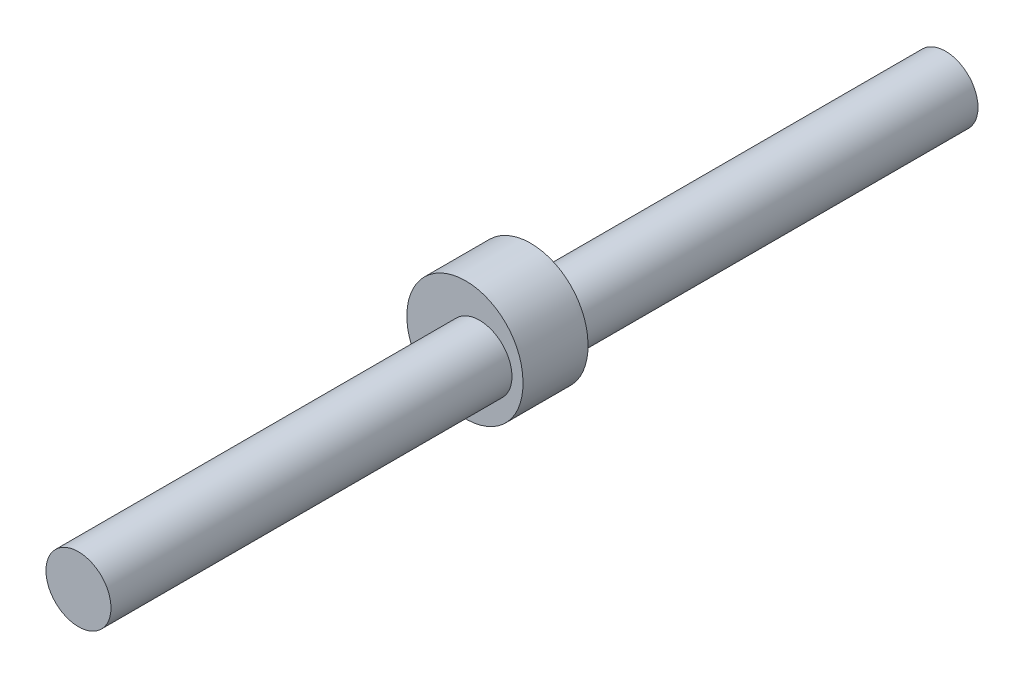
from build123d import *

# Parameters (mm, degrees)
BOSS_EXTRUDE1_DEPTH = 15
SKETCH3_R           = 15
BOSS_EXTRUDE2_DEPTH = 185


with BuildPart() as part:
    # Sketch2 → Boss-Extrude1 (new body, symmetric)
    with BuildSketch(Plane.XY):
        with BuildLine():
            add(Edge.make_bspline(
                [(20.1, 0), (20.099865774, 0.058549027), (20.099720739, 0.175649053), (20.098104632, 0.35129807), (20.095563684, 0.526947006), (20.091970511, 0.702595812), (20.087358573, 0.878244425), (20.08171813, 1.053892769), (20.075050658, 1.229540741), (20.06735461, 1.405188221), (20.058628907, 1.580835055), (20.048872259, 1.75648106), (20.038083185, 1.932126015), (20.026260057, 2.107769658), (20.013401137, 2.283411684), (19.999504479, 2.459051737), (19.984568023, 2.634689411), (19.968589576, 2.810324243), (19.951566785, 2.985955711), (19.933497107, 3.161583223), (19.914377952, 3.33720613), (19.894206459, 3.512823695), (19.872979789, 3.688435126), (19.850694789, 3.864039528), (19.827348341, 4.039635947), (19.802937009, 4.215223317), (19.777457405, 4.390800507), (19.750905849, 4.566366268), (19.723278664, 4.741919273), (19.694571969, 4.91745808), (19.66478173, 5.092981141), (19.633903929, 5.26848682), (19.601934228, 5.443973336), (19.568868351, 5.619438825), (19.534701772, 5.794881278), (19.499429942, 5.970298583), (19.463048166, 6.145688494), (19.425551633, 6.321048635), (19.386935424, 6.496376501), (19.347194523, 6.671669451), (19.306323839, 6.846924712), (19.264318125, 7.022139355), (19.221172104, 7.197310324), (19.176880377, 7.372434409), (19.131437416, 7.547508239), (19.084837698, 7.722528316), (19.037075545, 7.897490963), (18.988145195, 8.072392347), (18.938040965, 8.247228523), (18.886756533, 8.421995197), (18.834287426, 8.596688547), (18.780622304, 8.771302301), (18.72577487, 8.945838447), (18.669665072, 9.120267351), (18.612563037, 9.294676754), (18.552908395, 9.47024671), (18.49510864, 9.646799726), (18.434348602, 9.820938051), (18.36994419, 9.992344857), (18.307843693, 10.164870403), (18.242971673, 10.338476608), (18.177103311, 10.512044321), (18.109904186, 10.685447483), (18.041455828, 10.858711534), (17.971728109, 11.031821017), (17.900720772, 11.204771166), (17.828425593, 11.377554127), (17.754836457, 11.550162616), (17.679946664, 11.722588933), (17.603749748, 11.89482527), (17.526239092, 12.06686355), (17.447408186, 12.238695539), (17.36725053, 12.410312791), (17.285759627, 12.581706653), (17.20292898, 12.752868254), (17.118752183, 12.923788549), (17.033222829, 13.094458269), (16.946334525, 13.264867929), (16.858080999, 13.435007876), (16.768455925, 13.604868196), (16.677453116, 13.774438817), (16.585066409, 13.943709441), (16.491289677, 14.112669552), (16.396116902, 14.281308452), (16.299542137, 14.449615239), (16.201559426, 14.617578748), (16.102163051, 14.785187708), (16.001347186, 14.952430526), (15.899106263, 15.119295513), (15.795434709, 15.285770703), (15.690327065, 15.45184395), (15.583777996, 15.617502909), (15.47578225, 15.782735028), (15.366334707, 15.947527563), (15.255430333, 16.111867546), (15.143064252, 16.275741839), (15.02923168, 16.439137087), (14.91392799, 16.602039762), (14.797148632, 16.764436094), (14.678889274, 16.926312176), (14.559145672, 17.087653872), (14.437913705, 17.248446842), (14.315189508, 17.408676632), (14.190969236, 17.568328501), (14.065249313, 17.727387602), (13.938026234, 17.885838841), (13.809296756, 18.043667013), (13.679057749, 18.200856691), (13.547306243, 18.357392252), (13.414039495, 18.513257936), (13.279254941, 18.668437811), (13.142950177, 18.822915748), (13.005122991, 18.976675459), (12.865771422, 19.129700525), (12.724893628, 19.281974306), (12.58248804, 19.433480052), (12.438553258, 19.584200834), (12.293088121, 19.734119586), (12.146091642, 19.883219057), (11.997563117, 20.031481899), (11.847501999, 20.178890567), (11.695908009, 20.325427414), (11.542781108, 20.47107466), (11.388121432, 20.615814332), (11.231929424, 20.759628397), (11.074205735, 20.902498669), (10.914951256, 21.044406817), (10.754167123, 21.1853344), (10.591854769, 21.325262905), (10.428015807, 21.464173631), (10.262652172, 21.602047825), (10.09576602, 21.738866602), (9.927359791, 21.874610989), (9.757436183, 22.009261915), (9.585998175, 22.142800224), (9.413048988, 22.275206636), (9.238592168, 22.406461843), (9.06263147, 22.536546381), (8.885171021, 22.665440819), (8.706215125, 22.793125526), (8.525768463, 22.919580917), (8.343835953, 23.044787284), (8.160422816, 23.168724867), (7.975534557, 23.291373853), (7.789177006, 23.412714421), (7.601356249, 23.53272665), (7.41207869, 23.651390598), (7.221351043, 23.768686319), (7.029180284, 23.884593753), (6.83557384, 23.999093123), (6.640538892, 24.11216347), (6.444084952, 24.223788095), (6.246214385, 24.333934475), (6.046957582, 24.442629003), (5.846241724, 24.549677838), (5.644381692, 24.65571143), (5.440242271, 24.758273935), (5.239563697, 24.865693275), (5.023439999, 24.945695215), (4.826141087, 25.06584418), (4.612962346, 25.158738273), (4.403542937, 25.256252359), (4.191880407, 25.350222834), (3.979167353, 25.443009062), (3.76509837, 25.533951725), (3.549771111, 25.623202972), (3.33317534, 25.710697009), (3.115330183, 25.796426605), (2.896247307, 25.880368943), (2.675940792, 25.9625055), (2.454424469, 26.042816686), (2.231712642, 26.121283305), (2.007819903, 26.197886195), (1.782761169, 26.272606306), (1.556551672, 26.345424686), (1.329206969, 26.416322508), (1.100742936, 26.485281071), (0.871175764, 26.552281772), (0.640521955, 26.617306136), (0.408798345, 26.680335879), (0.176022066, 26.741352785), (-0.057789425, 26.800338829), (-0.292618365, 26.857276111), (-0.528446671, 26.912146926), (-0.765255955, 26.964933709), (-1.003027528, 27.015619021), (-1.241742381, 27.064185674), (-1.481381204, 27.110616627), (-1.721924396, 27.154894966), (-1.963352029, 27.197004092), (-2.205643904, 27.236927456), (-2.448779506, 27.274648812), (-2.692738029, 27.310152088), (-2.937498379, 27.343421418), (-3.183039165, 27.374441155), (-3.429338715, 27.403195846), (-3.676375062, 27.429670336), (-3.924125967, 27.45384961), (-4.172568899, 27.475718997), (-4.421681065, 27.495263919), (-4.671439381, 27.512470213), (-4.921820505, 27.527323809), (-5.172800816, 27.539811052), (-5.424356437, 27.54991839), (-5.676463224, 27.557632646), (-5.929096774, 27.562940891), (-6.182232433, 27.565830436), (-6.435845291, 27.566288908), (-6.689910193, 27.564304203), (-6.944401738, 27.559864514), (-7.199294287, 27.552958347), (-7.454561959, 27.543574421), (-7.710178647, 27.531701902), (-7.96611801, 27.51733013), (-8.222353485, 27.500448822), (-8.478858291, 27.481048027), (-8.735605421, 27.459118017), (-8.99256767, 27.434649534), (-9.249717615, 27.407633537), (-9.507027633, 27.378061345), (-9.764469904, 27.34592463), (-10.022016412, 27.311215379), (-10.279638955, 27.273925972), (-10.537309142, 27.234049078), (-10.794998408, 27.191577752), (-11.052678005, 27.146505376), (-11.310319027, 27.098825733), (-11.567892392, 27.048532926), (-11.825368868, 26.995621466), (-12.082719055, 26.940086169), (-12.339913425, 26.881922307), (-12.59692228, 26.821125431), (-12.853715805, 26.757691547), (-13.110264048, 26.691617036), (-13.366536909, 26.62289858), (-13.622504201, 26.551533384), (-13.878135583, 26.477518895), (-14.133400635, 26.400853079), (-14.388268805, 26.321534201), (-14.642709465, 26.23956099), (-14.896691877, 26.154932547), (-15.150185206, 26.067648323), (-15.403158567, 25.977708298), (-15.655580969, 25.88511274), (-15.907421352, 25.789862354), (-16.158648628, 25.691958322), (-16.409231589, 25.591402107), (-16.659139033, 25.488195724), (-16.90833967, 25.382341515), (-17.156802186, 25.273842257), (-17.404495233, 25.162701146), (-17.651387454, 25.048921838), (-17.897447415, 24.932508307), (-18.142643727, 24.813465058), (-18.386944965, 24.691796969), (-18.63031968, 24.567509294), (-18.872736487, 24.440607852), (-19.114163919, 24.311098686), (-19.354570625, 24.178988466), (-19.593925203, 24.044284144), (-19.832196309, 23.906993164), (-20.069352629, 23.767123367), (-20.305362895, 23.624683046), (-20.54019588, 23.479680904), (-20.773820408, 23.332126063), (-21.006205376, 23.1820281), (-21.237319745, 23.02939701), (-21.467132532, 22.874243181), (-21.695612848, 22.716577447), (-21.922729913, 22.556411104), (-22.148452996, 22.393755819), (-22.37275146, 22.228623671), (-22.595594857, 22.061027268), (-22.816952744, 21.890979495), (-23.036794863, 21.718493763), (-23.255091059, 21.543583855), (-23.471811313, 21.366263995), (-23.686925735, 21.186548797), (-23.900404608, 21.004453339), (-24.1122183, 20.819993032), (-24.322337426, 20.633183806), (-24.530732675, 20.444041904), (-24.737374976, 20.25258405), (-24.942235365, 20.058827296), (-25.145285138, 19.862789191), (-25.346495725, 19.66448763), (-25.545838759, 19.463940922), (-25.743286071, 19.26116776), (-25.938809691, 19.056187237), (-26.132381924, 18.849018888), (-26.323975179, 18.639682542), (-26.513562203, 18.428198518), (-26.701115889, 18.214587446), (-26.886609429, 17.998870387), (-27.070016188, 17.781068717), (-27.251309853, 17.561204257), (-27.430464316, 17.339299167), (-27.607453764, 17.115375994), (-27.782252562, 16.889457592), (-27.954835486, 16.661567272), (-28.125177472, 16.43172863), (-28.293253803, 16.199965656), (-28.459039964, 15.966302634), (-28.622511868, 15.730764283), (-28.783645605, 15.493375588), (-28.942417628, 15.254161916), (-29.098804679, 15.013148955), (-29.25278381, 14.770362723), (-29.404332401, 14.525829559), (-29.553428175, 14.279576146), (-29.70004913, 14.031629444), (-29.844173668, 13.78201678), (-29.98578045, 13.530765734), (-30.124848547, 13.277904233), (-30.261357361, 13.023460488), (-30.395286607, 12.767462985), (-30.526616411, 12.509940529), (-30.65532723, 12.250922191), (-30.781399886, 11.99043732), (-30.9048156, 11.728515556), (-31.025555923, 11.465186781), (-31.14360283, 11.200481167), (-31.258938635, 10.934429121), (-31.371546073, 10.667061319), (-31.481408251, 10.398408671), (-31.588508705, 10.128502348), (-31.692831289, 9.857373723), (-31.794360344, 9.585054434), (-31.893080578, 9.311576326), (-31.988977089, 9.036971457), (-32.082035456, 8.761272119), (-32.172241584, 8.484510782), (-32.259581867, 8.206720144), (-32.344043052, 7.927933069), (-32.425612418, 7.648182648), (-32.504277546, 7.367502111), (-32.58002656, 7.085924904), (-32.652847894, 6.803484604), (-32.722730562, 6.520214993), (-32.789663892, 6.236149973), (-32.853637732, 5.951323625), (-32.914642334, 5.66577016), (-32.972668396, 5.379523929), (-33.027707075, 5.092619419), (-33.079749985, 4.805091242), (-33.128789184, 4.516974127), (-33.174817149, 4.228302911), (-33.217826887, 3.939112548), (-33.257811771, 3.649438079), (-33.294765744, 3.359314651), (-33.328683077, 3.068777482), (-33.359558578, 2.777861877), (-33.38738755, 2.486603218), (-33.412165666, 2.195036943), (-33.43388913, 1.903198556), (-33.45255462, 1.611123612), (-33.468159196, 1.318847708), (-33.480700497, 1.026406485), (-33.490176517, 0.733835612), (-33.49658582, 0.441170785), (-33.499927392, 0.148447719), (-33.500200618, -0.144297861), (-33.497405512, -0.437030225), (-33.491542393, -0.729713644), (-33.482612141, -1.022312397), (-33.470616065, -1.314790781), (-33.455556006, -1.607113116), (-33.437434145, -1.899243747), (-33.416253262, -2.191147058), (-33.392016538, -2.482787478), (-33.364727607, -2.774129479), (-33.334390618, -3.065137598), (-33.301010104, -3.355776424), (-33.264591197, -3.646010632), (-33.225139308, -3.935804952), (-33.182660469, -4.225124217), (-33.137161073, -4.513933339), (-33.088648025, -4.80219733), (-33.037128641, -5.089881303), (-32.982610729, -5.376950483), (-32.925102532, -5.663370213), (-32.864612715, -5.949105947), (-32.801150473, -6.234123291), (-32.734725349, -6.518387962), (-32.665347389, -6.801865835), (-32.593027076, -7.084522931), (-32.517775307, -7.366325417), (-32.439603458, -7.647239635), (-32.358523301, -7.927232087), (-32.27454704, -8.206269446), (-32.187687335, -8.484318573), (-32.097957232, -8.7613465), (-32.005370284, -9.037320484), (-31.909940341, -9.312207935), (-31.811681753, -9.585976498), (-31.7106093, -9.858594032), (-31.60673809, -10.130028583), (-31.500083705, -10.400248445), (-31.39066212, -10.669222137), (-31.278489679, -10.936918397), (-31.163583136, -11.203306205), (-31.0459597, -11.468354817), (-30.925636831, -11.732033677), (-30.802632522, -11.994312555), (-30.676965039, -12.255161426), (-30.548653088, -12.514550564), (-30.417715723, -12.772450506), (-30.284172343, -13.028832054), (-30.148042734, -13.283666303), (-30.009347094, -13.536924659), (-29.868105834, -13.788578748), (-29.724339882, -14.038600584), (-29.578070388, -14.286962411), (-29.429318923, -14.533636834), (-29.278107313, -14.778596716), (-29.124457787, -15.021815278), (-28.968392862, -15.263266036), (-28.809935384, -15.502922842), (-28.649108543, -15.740759892), (-28.485935771, -15.976751669), (-28.320440871, -16.21087304), (-28.152647927, -16.443099199), (-27.982581325, -16.673405694), (-27.810265676, -16.901768366), (-27.635725982, -17.128163503), (-27.458987457, -17.352567687), (-27.280075588, -17.574957874), (-27.099016143, -17.79531138), (-26.915835175, -18.013605923), (-26.730558939, -18.229819527), (-26.543213973, -18.443930638), (-26.353827073, -18.655918087), (-26.162425241, -18.865761055), (-25.969035745, -19.073439132), (-25.773686044, -19.278932262), (-25.576403838, -19.482220804), (-25.377217049, -19.683285513), (-25.17615379, -19.882107528), (-24.973242388, -20.07866839), (-24.768511359, -20.272950031), (-24.561989418, -20.464934789), (-24.353705468, -20.654605419), (-24.143688559, -20.841945054), (-23.931967965, -21.026937277), (-23.718573068, -21.209566028), (-23.503533462, -21.38981572), (-23.286878828, -21.567671101), (-23.068639086, -21.743117442), (-22.848844215, -21.916140331), (-22.627524362, -22.086725816), (-22.404709786, -22.254860354), (-22.180430903, -22.42053086), (-21.9547182, -22.583724618), (-21.727602289, -22.744429365), (-21.499113895, -22.902633256), (-21.269283816, -23.058324858), (-21.038142975, -23.211493192), (-20.805722334, -23.362127677), (-20.572052962, -23.510218173), (-20.337165969, -23.65575494), (-20.101092566, -23.798728715), (-19.863863997, -23.939130631), (-19.625511552, -24.07695223), (-19.386066581, -24.212185514), (-19.145560461, -24.344822887), (-18.904024612, -24.474857225), (-18.661490458, -24.602281756), (-18.417989453, -24.727090188), (-18.173553079, -24.849276665), (-17.928212787, -24.968835693), (-17.682000066, -25.085762261), (-17.434946374, -25.200051751), (-17.187083163, -25.311699987), (-16.938441869, -25.4207032), (-16.689053892, -25.527058027), (-16.438950615, -25.630761549), (-16.188163373, -25.731811258), (-15.936723454, -25.830205051), (-15.684662107, -25.925941255), (-15.432010512, -26.019018588), (-15.178799804, -26.109436208), (-14.925061035, -26.197193644), (-14.670825191, -26.28229087), (-14.416123161, -26.364728213), (-14.160985781, -26.44450649), (-13.90544377, -26.521626837), (-13.649527749, -26.596090812), (-13.393268247, -26.667900385), (-13.136695673, -26.737057898), (-12.879840336, -26.803566107), (-12.622732411, -26.867428122), (-12.365401957, -26.928647475), (-12.107878898, -26.98722807), (-11.850193014, -27.04317415), (-11.592373961, -27.096490412), (-11.334451232, -27.147181875), (-11.076454171, -27.195253916), (-10.818411971, -27.240712325), (-10.560353652, -27.283563212), (-10.302308078, -27.32381309), (-10.044303929, -27.361468787), (-9.78636971, -27.39653748), (-9.528533756, -27.429026802), (-9.270824191, -27.458944546), (-9.013268969, -27.486299023), (-8.755895835, -27.511098796), (-8.498732336, -27.533352756), (-8.241805813, -27.553070159), (-7.985143396, -27.570260561), (-7.728772003, -27.584933882), (-7.472718329, -27.597100301), (-7.21700885, -27.606770365), (-6.96166981, -27.613954893), (-6.706727227, -27.618665024), (-6.452206879, -27.620912192), (-6.198134307, -27.62070818), (-5.944534809, -27.618064927), (-5.691433435, -27.61299485), (-5.438854987, -27.605510467), (-5.186824011, -27.5956247), (-4.935364795, -27.583350683), (-4.684501368, -27.568701827), (-4.434257494, -27.551691834), (-4.184656669, -27.532334644), (-3.935722122, -27.51064441), (-3.687476801, -27.486635637), (-3.439943383, -27.460322983), (-3.193144271, -27.431721344), (-2.947101569, -27.40084596), (-2.701837117, -27.367712141), (-2.457372451, -27.332335544), (-2.213728826, -27.294731975), (-1.9709272, -27.254917499), (-1.728988241, -27.212908364), (-1.487932312, -27.168721038), (-1.247779493, -27.122372123), (-1.008549543, -27.073878517), (-0.770261927, -27.023257247), (-0.532935814, -26.970525489), (-0.29659005, -26.915700667), (-0.061243182, -26.858800332), (0.173086548, -26.799842187), (0.406381225, -26.738844154), (0.638623232, -26.675824242), (0.869795268, -26.610800635), (1.099880357, -26.543791685), (1.328861832, -26.47481586), (1.556723335, -26.403891729), (1.783448848, -26.331038059), (2.009022651, -26.256273679), (2.233429351, -26.17961755), (2.456653882, -26.101088763), (2.678681482, -26.020706476), (2.899497742, -25.938490016), (3.119088523, -25.854458678), (3.337440065, -25.768631994), (3.554538897, -25.681029492), (3.770371859, -25.591670756), (3.984926163, -25.500575552), (4.198189272, -25.407763556), (4.410149044, -25.313254672), (4.620793597, -25.217068728), (4.830111412, -25.119225679), (5.038091269, -25.019745489), (5.244722262, -24.918648153), (5.449993837, -24.815953763), (5.65389572, -24.711682366), (5.856417974, -24.605854066), (6.057550976, -24.498488989), (6.257285424, -24.38960728), (6.45561231, -24.279229059), (6.65252296, -24.167374482), (6.848009016, -24.054063711), (7.042062396, -23.939316844), (7.234675366, -23.823154034), (7.425840483, -23.705595392), (7.615550602, -23.586660989), (7.803798892, -23.466370886), (7.990578824, -23.344745115), (8.17588417, -23.221803674), (8.359708991, -23.097566496), (8.542047651, -22.972053483), (8.722894812, -22.845284495), (8.90224542, -22.717279324), (9.080094709, -22.588057704), (9.256438225, -22.45763933), (9.431271747, -22.326043764), (9.604591402, -22.193290575), (9.77639353, -22.059399175), (9.946674815, -21.924388972), (10.115432144, -21.788279204), (10.282662749, -21.651089105), (10.448364061, -21.512837739), (10.612533844, -21.373544136), (10.775170057, -21.233227153), (10.936270974, -21.091905597), (11.095835097, -20.949598142), (11.253861191, -20.806323354), (11.410348259, -20.662099664), (11.565295577, -20.51694541), (11.718702633, -20.370878772), (11.870569169, -20.223917814), (12.020895181, -20.076080483), (12.169680849, -19.927384552), (12.316926665, -19.77784772), (12.462633239, -19.627487452), (12.606801499, -19.476321146), (12.749432543, -19.32436602), (12.890527689, -19.171639131), (13.030088475, -19.018157393), (13.168116633, -18.863937555), (13.304614122, -18.708996219), (13.43958306, -18.553349796), (13.573025822, -18.397014582), (13.704944897, -18.240006639), (13.835343003, -18.082341888), (13.964223083, -17.924036114), (14.091588147, -17.765104831), (14.217441507, -17.60556349), (14.341786556, -17.445427279), (14.464626857, -17.284711211), (14.585966222, -17.12343018), (14.70580849, -16.96159879), (14.824157766, -16.799231546), (14.94101826, -16.636342727), (15.056394282, -16.472946397), (15.170290371, -16.309056487), (15.282711139, -16.144686682), (15.393661336, -15.979850478), (15.503145871, -15.814561192), (15.611169734, -15.648831928), (15.71773806, -15.482675596), (15.822856105, -15.316104919), (15.926529186, -15.149132371), (16.028762776, -14.981770266), (16.129562443, -14.814030714), (16.22893383, -14.645925608), (16.326882661, -14.477466624), (16.423414767, -14.308665251), (16.518536072, -14.139532767), (16.612252556, -13.970080245), (16.704570288, -13.800318551), (16.795495372, -13.630258334), (16.885034015, -13.45991005), (16.973192496, -13.289283956), (17.059977065, -13.118390059), (17.14539413, -12.947238214), (17.229450069, -12.775838031), (17.312151327, -12.604198927), (17.393504412, -12.432330123), (17.473515816, -12.260240617), (17.552192074, -12.087939202), (17.629539795, -11.915434496), (17.705565531, -11.742734874), (17.780275887, -11.569848528), (17.853677514, -11.396783463), (17.925776979, -11.223547442), (17.996580952, -11.050148075), (18.066096037, -10.876592741), (18.134328866, -10.70288864), (18.201286019, -10.529042759), (18.266974111, -10.355061907), (18.331399725, -10.180952697), (18.394569388, -10.006721534), (18.45648965, -9.832374655), (18.517167007, -9.657918098), (18.576607914, -9.483357711), (18.634818812, -9.308699168), (18.69180607, -9.133947948), (18.747576036, -8.959109359), (18.802134979, -8.78418852), (18.85548918, -8.60919039), (18.907644782, -8.434119734), (18.958607921, -8.258981158), (19.008384649, -8.083779092), (19.056980963, -7.908517804), (19.104402754, -7.733201383), (19.15065592, -7.557833782), (19.195746183, -7.382418763), (19.239679256, -7.206959953), (19.282460728, -7.031460813), (19.324096134, -6.855924661), (19.364590869, -6.680354653), (19.4039503, -6.504753816), (19.442179636, -6.329125016), (19.479284033, -6.153470993), (19.515268527, -5.977794342), (19.550138047, -5.802097526), (19.583897426, -5.62638288), (19.616551347, -5.450652601), (19.648104465, -5.274908779), (19.67856121, -5.099153364), (19.707925978, -4.923388202), (19.736203045, -4.747615023), (19.763396479, -4.571835432), (19.78951033, -4.396050947), (19.814548451, -4.220262966), (19.838514611, -4.044472799), (19.861412394, -3.868681646), (19.883245323, -3.692890627), (19.904016705, -3.517100761), (19.923729802, -3.341312992), (19.942387638, -3.165528171), (19.959993188, -2.98974708), (19.976549213, -2.813970419), (19.992058413, -2.638198827), (20.006523227, -2.462432862), (20.019946074, -2.286673034), (20.03232915, -2.110919784), (20.043674515, -1.935173502), (20.053984118, -1.759434526), (20.063259675, -1.583703144), (20.071502907, -1.407979609), (20.078714939, -1.232264119), (20.084898318, -1.056556876), (20.090049689, -0.880857918), (20.09556544, -0.646623319), (20.098930115, -0.412379866), (20.100532579, -0.177317617), (20.100136134, -0.059381321), (20.1, 0)],
                knots=[0, 0, 0, 0, 0.001026665, 0.002053364, 0.003080133, 0.004107006, 0.005134017, 0.006161203, 0.007188596, 0.008216232, 0.009244145, 0.010272371, 0.011300942, 0.012329894, 0.013359261, 0.014389077, 0.015419376, 0.016450193, 0.017481561, 0.018513515, 0.019546087, 0.020579313, 0.021613224, 0.022647856, 0.02368324, 0.024719411, 0.025756402, 0.026794245, 0.027832972, 0.028872618, 0.029913214, 0.030954792, 0.031997385, 0.033041024, 0.034085742, 0.03513157, 0.03617854, 0.037226682, 0.038276028, 0.039326608, 0.040378454, 0.041431596, 0.042486063, 0.043541887, 0.044599096, 0.04565772, 0.046717789, 0.047779332, 0.048842378, 0.049906955, 0.050973092, 0.052040816, 0.053110157, 0.054181141, 0.055253796, 0.056328149, 0.057432601, 0.058511319, 0.05956189, 0.060643302, 0.061726544, 0.062811642, 0.063898621, 0.064987505, 0.066078321, 0.067171092, 0.068265842, 0.069362595, 0.070461376, 0.071562207, 0.072665111, 0.073770112, 0.074877231, 0.075986492, 0.077097915, 0.078211523, 0.079327336, 0.080445377, 0.081565665, 0.082688221, 0.083813066, 0.084940218, 0.086069698, 0.087201525, 0.088335718, 0.089472296, 0.090611276, 0.091752678, 0.092896518, 0.094042815, 0.095191585, 0.096342845, 0.097496612, 0.098652903, 0.099811732, 0.100973117, 0.102137072, 0.103303612, 0.104472752, 0.105644507, 0.106818891, 0.107995917, 0.109175601, 0.110357953, 0.111542989, 0.11273072, 0.113921159, 0.115114319, 0.11631021, 0.117508845, 0.118710235, 0.11991439, 0.121121323, 0.122331042, 0.123543559, 0.124758883, 0.125977023, 0.12719799, 0.128421792, 0.129648437, 0.130877935, 0.132110293, 0.13334552, 0.134583623, 0.13582461, 0.137068487, 0.138315262, 0.13956494, 0.14081753, 0.142073035, 0.143331463, 0.144592819, 0.145857107, 0.147124334, 0.148394503, 0.14966762, 0.150943689, 0.152222712, 0.153504696, 0.154789641, 0.156077553, 0.157368434, 0.158662287, 0.159959114, 0.161258917, 0.162561699, 0.163867461, 0.165176205, 0.166487932, 0.167802643, 0.169120339, 0.170441021, 0.171764689, 0.173091342, 0.174420982, 0.175753608, 0.177089219, 0.178427814, 0.179740702, 0.181116242, 0.182463784, 0.183814305, 0.185167803, 0.186524277, 0.187883724, 0.189246141, 0.190611526, 0.191979876, 0.193351188, 0.194725458, 0.196102683, 0.19748286, 0.198865984, 0.200252051, 0.201641057, 0.203032997, 0.204427867, 0.205825662, 0.207226377, 0.208630006, 0.210036544, 0.211445985, 0.212858324, 0.214273554, 0.21569167, 0.217112664, 0.21853653, 0.219963262, 0.221392853, 0.222825295, 0.224260581, 0.225698704, 0.227139657, 0.22858343, 0.230030017, 0.23147941, 0.232931599, 0.234386577, 0.235844335, 0.237304864, 0.238768155, 0.240234199, 0.241702987, 0.24317451, 0.244648757, 0.24612572, 0.247605387, 0.24908775, 0.250572798, 0.252060521, 0.253550908, 0.255043949, 0.256539633, 0.258037948, 0.259538884, 0.261042431, 0.262548575, 0.264057306, 0.265568613, 0.267082483, 0.268598905, 0.270117867, 0.271639356, 0.27316336, 0.274689867, 0.276218864, 0.277750339, 0.279284279, 0.28082067, 0.282359501, 0.283900757, 0.285444425, 0.286990492, 0.288538945, 0.290089769, 0.291642952, 0.293198478, 0.294756335, 0.296316508, 0.297878982, 0.299443744, 0.301010778, 0.302580071, 0.304151608, 0.305725374, 0.307301354, 0.308879533, 0.310459895, 0.312042427, 0.313627112, 0.315213935, 0.31680288, 0.318393933, 0.319987076, 0.321582295, 0.323179574, 0.324778896, 0.326380246, 0.327983606, 0.329588962, 0.331196297, 0.332805593, 0.334416835, 0.336030006, 0.33764509, 0.339262069, 0.340880926, 0.342501645, 0.344124208, 0.345748599, 0.3473748, 0.349002794, 0.350632564, 0.352264091, 0.353897359, 0.35553235, 0.357169046, 0.358807429, 0.360447482, 0.362089187, 0.363732525, 0.365377479, 0.36702403, 0.368672161, 0.370321853, 0.371973087, 0.373625846, 0.375280111, 0.376935863, 0.378593083, 0.380251754, 0.381911856, 0.383573371, 0.38523628, 0.386900563, 0.388566203, 0.390233179, 0.391901474, 0.393571067, 0.395241939, 0.396914072, 0.398587446, 0.400262042, 0.401937841, 0.403614822, 0.405292966, 0.406972255, 0.408652668, 0.410334186, 0.412016789, 0.413700457, 0.415385171, 0.41707091, 0.418757656, 0.420445387, 0.422134085, 0.423823729, 0.4255143, 0.427205776, 0.428898139, 0.430591367, 0.432285441, 0.433980342, 0.435676047, 0.437372538, 0.439069793, 0.440767794, 0.442466518, 0.444165946, 0.445866058, 0.447566833, 0.449268251, 0.450970291, 0.452672932, 0.454376155, 0.456079938, 0.457784261, 0.459489104, 0.461194445, 0.462900265, 0.464606542, 0.466313256, 0.468020386, 0.469727912, 0.471435812, 0.473144066, 0.474852654, 0.476561554, 0.478270746, 0.479980208, 0.481689921, 0.483399863, 0.485110014, 0.486820352, 0.488530857, 0.490241508, 0.491952285, 0.493663165, 0.495374129, 0.497085156, 0.498796224, 0.500507313, 0.502218402, 0.503929471, 0.505640497, 0.507351461, 0.509062342, 0.510773118, 0.512483769, 0.514194274, 0.515904612, 0.517614763, 0.519324705, 0.521034418, 0.522743881, 0.524453072, 0.526161972, 0.52787056, 0.529578814, 0.531286714, 0.53299424, 0.53470137, 0.536408084, 0.538114361, 0.539820181, 0.541525522, 0.543230365, 0.544934688, 0.546638471, 0.548341694, 0.550044335, 0.551746375, 0.553447793, 0.555148568, 0.55684868, 0.558548108, 0.560246833, 0.561944833, 0.563642089, 0.565338579, 0.567034285, 0.568729185, 0.570423259, 0.572116488, 0.57380885, 0.575500327, 0.577190897, 0.578880541, 0.580569239, 0.582256971, 0.583943716, 0.585629456, 0.58731417, 0.588997838, 0.590680441, 0.592361958, 0.594042371, 0.59572166, 0.597399805, 0.599076786, 0.600752584, 0.60242718, 0.604100554, 0.605772687, 0.60744356, 0.609113153, 0.610781447, 0.612448423, 0.614114063, 0.615778347, 0.617441255, 0.61910277, 0.620762872, 0.622421543, 0.624078764, 0.625734516, 0.62738878, 0.629041539, 0.630692774, 0.632342465, 0.633990596, 0.635637147, 0.637282101, 0.63892544, 0.640567144, 0.642207197, 0.643845581, 0.645482276, 0.647117267, 0.648750535, 0.650382063, 0.652011832, 0.653639826, 0.655266027, 0.656890418, 0.658512981, 0.6601337, 0.661752558, 0.663369537, 0.66498462, 0.666597791, 0.668209033, 0.66981833, 0.671425664, 0.67303102, 0.674634381, 0.67623573, 0.677835052, 0.679432331, 0.68102755, 0.682620694, 0.684211746, 0.685800692, 0.687387515, 0.6889722, 0.690554731, 0.692135094, 0.693713273, 0.695289252, 0.696863018, 0.698434555, 0.700003848, 0.701570883, 0.703135644, 0.704698119, 0.706258291, 0.707816148, 0.709371675, 0.710924857, 0.712475681, 0.714024134, 0.715570201, 0.71711387, 0.718655126, 0.720193956, 0.721730348, 0.723264287, 0.724795762, 0.726324759, 0.727851266, 0.729375271, 0.73089676, 0.732415721, 0.733932143, 0.735446013, 0.73695732, 0.738466051, 0.739972196, 0.741475742, 0.742976678, 0.744474994, 0.745970677, 0.747463718, 0.748954105, 0.750441828, 0.751926876, 0.753409239, 0.754888907, 0.756365869, 0.757840117, 0.759311639, 0.760780427, 0.762246472, 0.763709763, 0.765170292, 0.766628049, 0.768083027, 0.769535217, 0.770984609, 0.772431196, 0.77387497, 0.775315922, 0.776754045, 0.778189331, 0.779621773, 0.781051364, 0.782478096, 0.783901963, 0.785322957, 0.786741072, 0.788156302, 0.789568641, 0.790978082, 0.79238462, 0.793788249, 0.795188964, 0.796586759, 0.797981629, 0.799373569, 0.800762575, 0.802148643, 0.803531766, 0.804911943, 0.806289168, 0.807663439, 0.80903475, 0.8104031, 0.811768486, 0.813130903, 0.81449035, 0.815846823, 0.817200322, 0.818550843, 0.819898385, 0.821242946, 0.822584524, 0.82392312, 0.825258731, 0.826591356, 0.827920996, 0.82924765, 0.830571318, 0.831892, 0.833209696, 0.834524407, 0.835836134, 0.837144878, 0.83845064, 0.839753422, 0.841053225, 0.842350052, 0.843643905, 0.844934785, 0.846222697, 0.847507643, 0.848789626, 0.85006865, 0.851344719, 0.852617835, 0.853888005, 0.855155232, 0.85641952, 0.857680876, 0.858939304, 0.860194809, 0.861447398, 0.862697077, 0.863943852, 0.865187729, 0.866428715, 0.867666818, 0.868902045, 0.870134404, 0.871363902, 0.872590547, 0.873814349, 0.875035316, 0.876253456, 0.87746878, 0.878681297, 0.879891016, 0.881097949, 0.882302104, 0.883503494, 0.884702129, 0.88589802, 0.88709118, 0.888281619, 0.88946935, 0.890654385, 0.891836738, 0.893016421, 0.894193448, 0.895367832, 0.896539587, 0.897708727, 0.898875267, 0.900039222, 0.901200606, 0.902359436, 0.903515727, 0.904669494, 0.905820754, 0.906969524, 0.908115821, 0.909259661, 0.910401062, 0.911540043, 0.91267662, 0.913810813, 0.914942641, 0.916072121, 0.917199273, 0.918324118, 0.919446674, 0.920566962, 0.921685002, 0.922800816, 0.923914424, 0.925025847, 0.926135107, 0.927242227, 0.928347227, 0.929450132, 0.930550963, 0.931649743, 0.932746497, 0.933841247, 0.934934018, 0.936024833, 0.937113718, 0.938200697, 0.939285795, 0.940369037, 0.941450449, 0.942530057, 0.943607887, 0.944683965, 0.945758318, 0.946830973, 0.947901957, 0.948971297, 0.950039022, 0.951105159, 0.952169736, 0.953232781, 0.954294324, 0.955354394, 0.956413018, 0.957470227, 0.958526051, 0.959580518, 0.960633659, 0.961685505, 0.962736086, 0.963785432, 0.964833574, 0.965880543, 0.966926371, 0.967971089, 0.969014729, 0.970057322, 0.9710989, 0.972139496, 0.973179141, 0.974217869, 0.975255712, 0.976292702, 0.977328873, 0.978364258, 0.979398889, 0.980432801, 0.981466027, 0.982498599, 0.983530553, 0.984561921, 0.985592738, 0.986623037, 0.987652853, 0.98868222, 0.989711172, 0.990739743, 0.991767968, 0.992795882, 0.993823518, 0.994850911, 0.995878096, 0.997931972, 0.998958741, 1, 1, 1, 1], degree=3))
        make_face()
    extrude(amount=BOSS_EXTRUDE1_DEPTH, both=True)

    # Sketch3 → Boss-Extrude2 (add)
    with BuildSketch(Plane.XY.offset(15)):
        Circle(SKETCH3_R)
    boss_extrude2 = extrude(amount=BOSS_EXTRUDE2_DEPTH)

    # Mirror1: Boss-Extrude2 across plane
    add(boss_extrude2.mirror(Plane.XY))


solid = part.part
